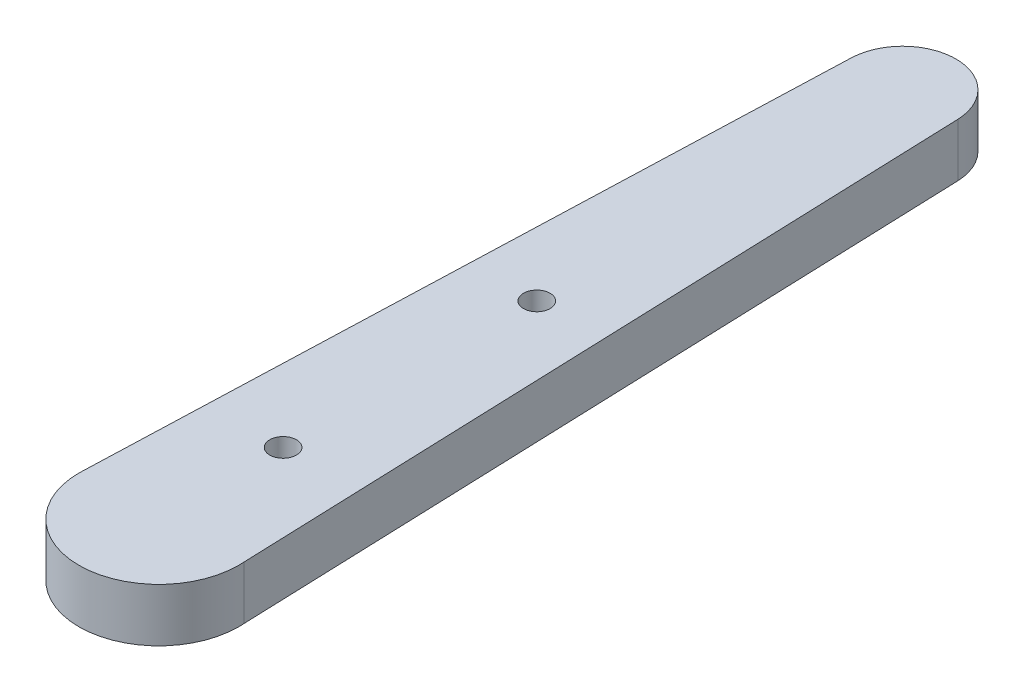
from build123d import *

# Parameters (mm, degrees)
SKETCH1_R           = 3
BOSS_EXTRUDE1_DEPTH = 2
BOSS_EXTRUDE4_DEPTH = 2
SKETCH4_R           = 0.5
CUT_EXTRUDE1_DEPTH  = 2


with BuildPart() as part:
    # Sketch1 → Boss-Extrude1 (new body)
    with BuildSketch(Plane(origin=(0, 0, 0), x_dir=(1, 0, 0), z_dir=(0, 1, 0))):
        Circle(SKETCH1_R)
    extrude(amount=BOSS_EXTRUDE1_DEPTH)

    # Sketch3 → Boss-Extrude4 (add)
    with BuildSketch(Plane(origin=(0, 2, 0), x_dir=(1, 0, 0), z_dir=(0, 1, 0))):
        with BuildLine():
            ThreePointArc((-2.992341362, 0.214226915), (9.2675e-05, -2.999999999), (2.992328121, 0.214411791))
            Line((2.992328121, 0.214411791), (1.998320796, 27.995599459))
            ThreePointArc((1.998320796, 27.995599459), (-0.000428771, 29.924085477), (-1.999123301, 27.995542419))
            Line((-1.999123301, 27.995542419), (-2.992341362, 0.214226915))
        make_face()
    extrude(amount=-BOSS_EXTRUDE4_DEPTH)

    # Sketch4 → Cut-Extrude1 (cut)
    with BuildSketch(Plane(origin=(0, 2, 0), x_dir=(1, 0, 0), z_dir=(0, 1, 0))):
        with Locations((-0.000203324, 14.190099999)):
            Circle(SKETCH4_R)
        with Locations((-6.6844e-05, 4.6651)):
            Circle(SKETCH4_R)
    extrude(amount=-CUT_EXTRUDE1_DEPTH, mode=Mode.SUBTRACT)


solid = part.part
